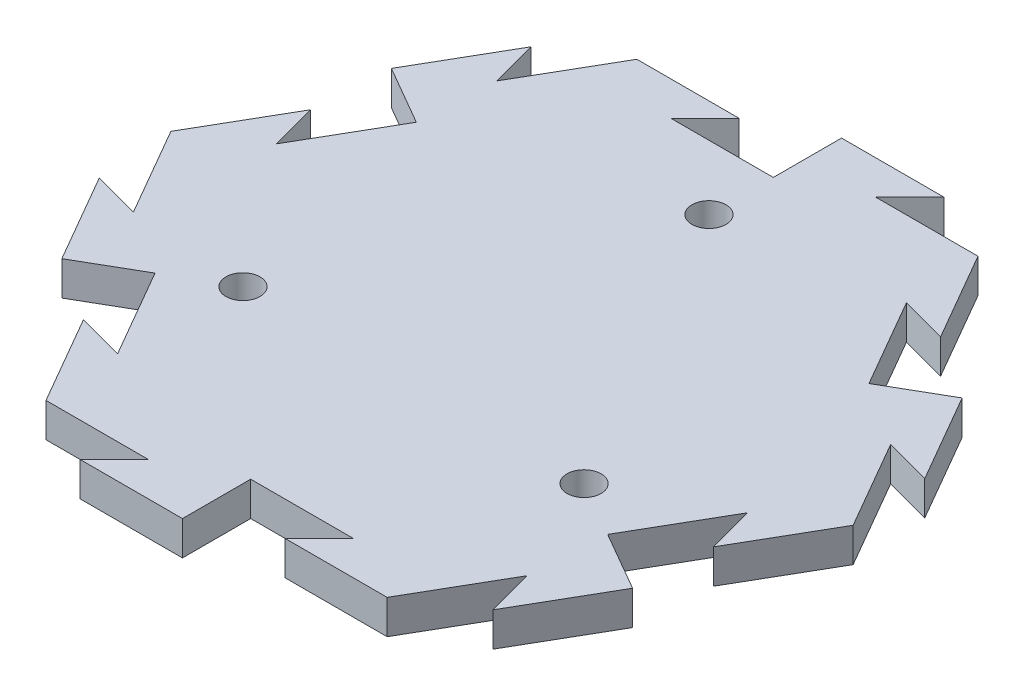
from build123d import *

# Parameters (mm, degrees)
BOSS_EXTRUDE1_DEPTH = 6.35
SKETCH9_R           = 3.175
CUT_EXTRUDE3_DEPTH  = 85.242269675
CIRPATTERN6_COUNT   = 3
CUT_EXTRUDE4_DEPTH  = 85.242269675
BOSS_EXTRUDE4_DEPTH = 6.35
CIRPATTERN7_COUNT   = 6


with BuildPart() as part:
    # Sketch1 → Boss-Extrude1 (new body)
    with BuildSketch(Plane(origin=(0, 0, 0), x_dir=(1, 0, 0), z_dir=(0, 1, 0))):
        Polygon((63.5, 0), (31.75, 54.99261314), (-31.75, 54.99261314), (-63.5, 0), (-31.75, -54.99261314), (31.75, -54.99261314), align=None)
    extrude(amount=-BOSS_EXTRUDE1_DEPTH)

    # Sketch9 → Cut-Extrude3 (cut, through all)
    with BuildSketch(Plane(origin=(0, 0, 0), x_dir=(1, 0, 0), z_dir=(0, 1, 0))):
        with Locations((-31.75, -18.330871047)):
            Circle(SKETCH9_R)
    cut_extrude3 = extrude(amount=-CUT_EXTRUDE3_DEPTH, mode=Mode.SUBTRACT)

    # CirPattern6: Cut-Extrude3 ×3 about axis
    cirpattern6_axis = Axis((0, 0, 0), (0, 1, 0))
    for i in range(1, CIRPATTERN6_COUNT):
        add(cut_extrude3.rotate(cirpattern6_axis, i * 360 / CIRPATTERN6_COUNT), mode=Mode.SUBTRACT)

    # Sketch10 → Cut-Extrude4 (cut, through all)
    with BuildSketch(Plane(origin=(0, 0, 0), x_dir=(1, 0, 0), z_dir=(0, 1, 0))):
        Polygon((41.275, 38.494829198), (32.600738686, 40.819090512), (42.125738686, 24.32130657), (47.625, 27.49630657), align=None)
    cut_extrude4 = extrude(amount=-CUT_EXTRUDE4_DEPTH, mode=Mode.SUBTRACT)

    # Sketch11 → Boss-Extrude4 (add)
    with BuildSketch(Plane(origin=(0, 0, 0), x_dir=(1, 0, 0), z_dir=(0, 1, 0))):
        Polygon((47.625, 27.49630657), (53.124261314, 30.67130657), (62.649261314, 14.173522628), (53.975, 16.497783942), align=None)
    boss_extrude4 = extrude(amount=-BOSS_EXTRUDE4_DEPTH)

    # CirPattern7: Cut-Extrude4, Boss-Extrude4 ×6 about axis
    cirpattern7_axis = Axis((0, 0, 0), (0, 1, 0))
    add([cut_extrude4.rotate(cirpattern7_axis, i * 360 / CIRPATTERN7_COUNT) for i in range(1, CIRPATTERN7_COUNT)], mode=Mode.SUBTRACT)
    add([boss_extrude4.rotate(cirpattern7_axis, i * 360 / CIRPATTERN7_COUNT) for i in range(1, CIRPATTERN7_COUNT)])


solid = part.part
